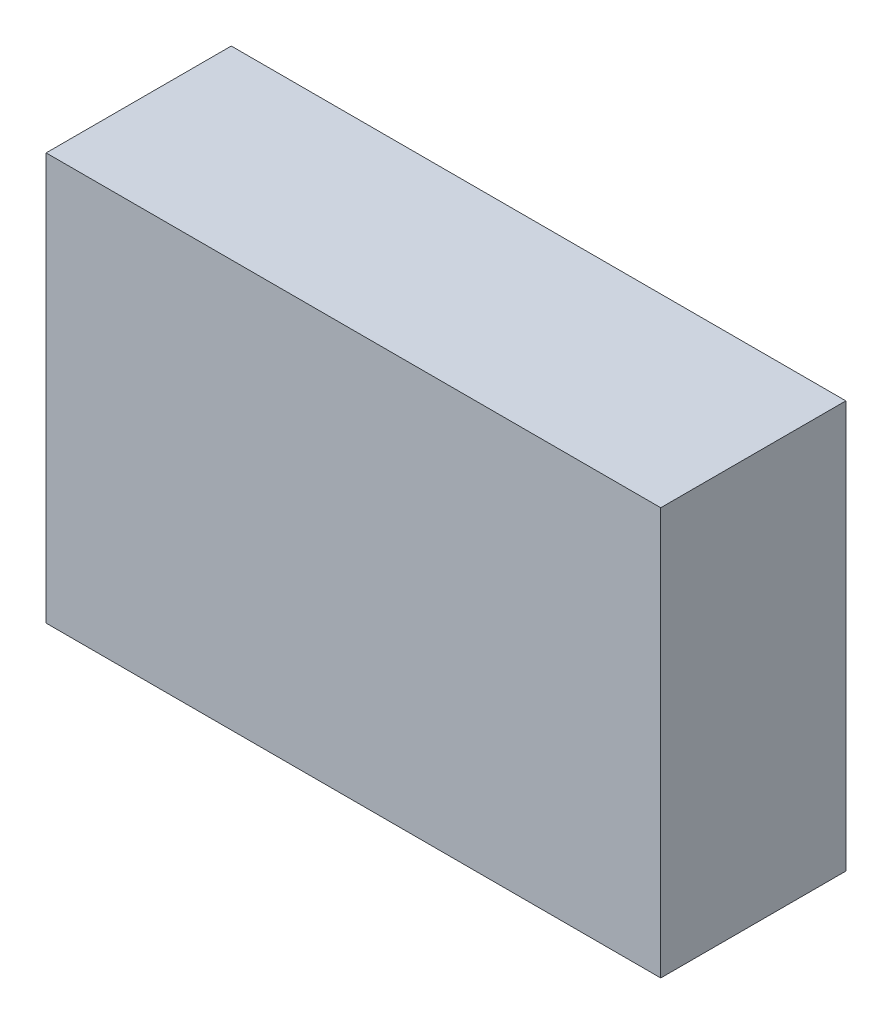
from build123d import *

# Parameters (mm, degrees)
SKICA1_W                = 166
SKICA1_H                = 110
P_IDAT_VYSUNUT_M1_DEPTH = 50


with BuildPart() as part:
    # Skica1 → Přidat vysunutím1 (new body)
    with BuildSketch(Plane.XY):
        with Locations((83, 55)):
            Rectangle(SKICA1_W, SKICA1_H)
    extrude(amount=P_IDAT_VYSUNUT_M1_DEPTH)


solid = part.part
